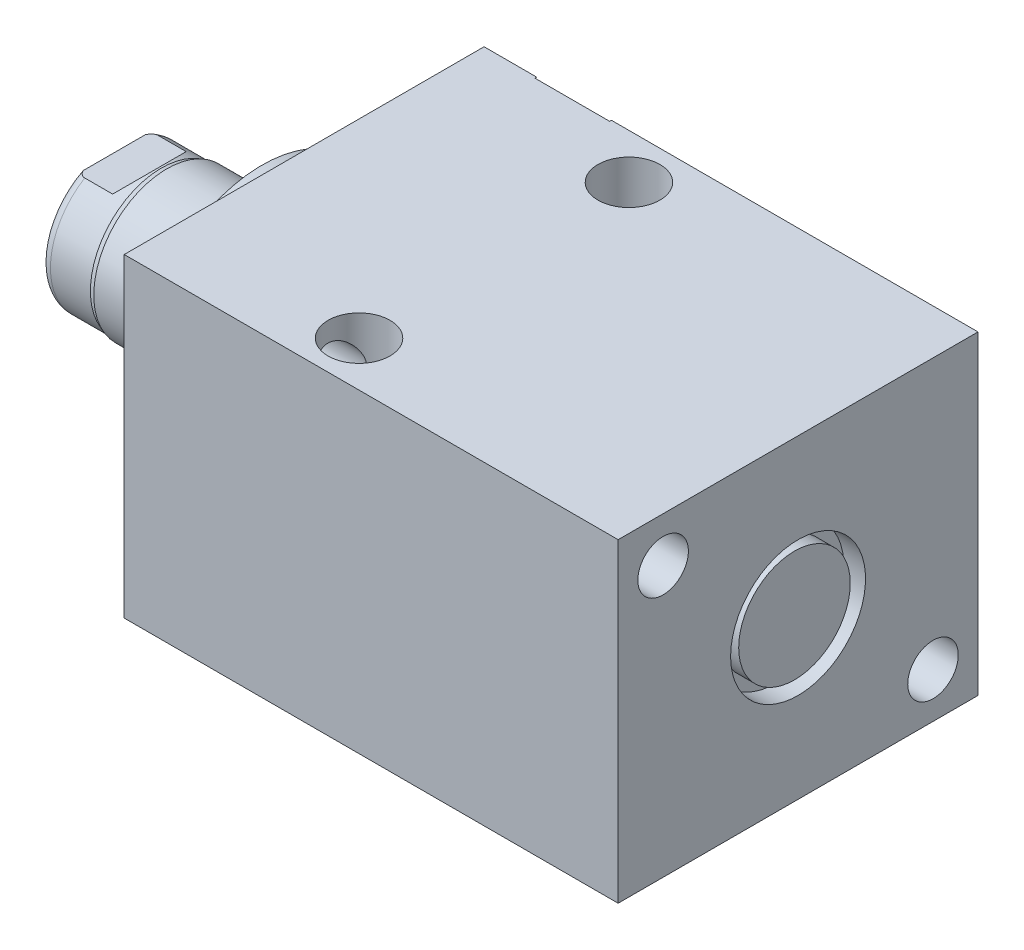
from build123d import *

# Parameters (mm, degrees)
SKETCH1_W          = 50.8
SKETCH1_H          = 44.45
EXTRUDE1_DEPTH     = 69.723
SKETCH5_R          = 17.4625
EXTRUDE2_DEPTH     = 5.969
SKETCH6_W          = 10.31875
SKETCH6_H          = 20.828
CUT_EXTRUDE4_DEPTH = 30.48
SKETCH13_R         = 7.874
EXTRUDE3_DEPTH     = 2.54
HOLE1_D            = 7.1374
HOLE1_DEPTH        = 69.723
HOLE2_D            = 8.7376
HOLE2_DEPTH        = 44.45
SKETCH18_R         = 7.874
EXTRUDE4_DEPTH     = 2.54


with BuildPart() as part:
    # Sketch1 → Extrude1 (new body)
    with BuildSketch(Plane(origin=(0, 0, 0), x_dir=(0, 0, -1), z_dir=(1, 0, 0))):
        Rectangle(SKETCH1_W, SKETCH1_H)
    extrude(amount=EXTRUDE1_DEPTH)

    # S2D0002 → Cut-Revolve1 (revolve, cut)
    with BuildSketch(Plane(origin=(0, 14.3002, 0), x_dir=(-1, 0, 0), z_dir=(0, 1, 0)), mode=Mode.PRIVATE) as cut_revolve1_sk:
        Polygon((-18.8849, -25.146), (-22.225, -25.146), (-22.225, -25.4), (-12.7, -25.4), (-12.7, -11.176), (-17.6784, -11.176), (-17.6784, -21.929393135), (-18.342306865, -22.5933), align=None)
    revolve(cut_revolve1_sk.sketch.rotate(Axis((12.7, 14.3002, -19.13842003), (0, 0, 1)), 180), axis=Axis((12.7, 14.3002, -19.13842003), (0, 0, 1)), mode=Mode.SUBTRACT)  # turned: the seam where the file's is

    # Sketch3 → Cut-Revolve2 (revolve, cut)
    with BuildSketch(Plane(origin=(41.148, 0, -25.146), x_dir=(1, 0, 0), z_dir=(0, 1, 0))):
        Polygon((18.8849, 0), (22.225, 0), (22.225, 0.254), (12.7, 0.254), (12.7, -13.97), (17.6784, -13.97), (17.6784, -3.216606865), (18.342306865, -2.5527), align=None)
    revolve(axis=Axis((53.848, 0, -3.189624441), (0, 0, -1)), mode=Mode.SUBTRACT)

    # Sketch4 → Cut-Revolve3 (revolve, cut)
    with BuildSketch(Plane(origin=(53.975, 0, 0), x_dir=(0, -1, 0), z_dir=(0, 0, 1)), mode=Mode.PRIVATE) as cut_revolve3_sk:
        Polygon((6.1849, 12.7), (9.525, 12.7), (9.525, 15.748), (0, 15.748), (0, 1.3462), (4.9784, 1.3462), (4.9784, 9.483393135), (5.642306865, 10.1473), align=None)
    revolve(cut_revolve3_sk.sketch.rotate(Axis((38.879609832, 0, 0), (1, 0, 0)), 270), axis=Axis((38.879609832, 0, 0), (1, 0, 0)), mode=Mode.SUBTRACT)  # turned: the seam where the file's is

    # Sketch5 → Extrude2 (add)
    with BuildSketch(Plane.ZY):
        Circle(SKETCH5_R)
    extrude(amount=EXTRUDE2_DEPTH)

    # Sketch6 → Revolve1 (revolve)
    with BuildSketch(Plane(origin=(0, 0, 0), x_dir=(0, 0, 1), z_dir=(0, -1, 0)), mode=Mode.PRIVATE) as revolve1_sk:
        with Locations((-5.159375, 16.383)):
            Rectangle(SKETCH6_W, SKETCH6_H)
    revolve(revolve1_sk.sketch.rotate(Axis((5.754582971, 0, 0), (-1, 0, 0)), 180), axis=Axis((5.754582971, 0, 0), (-1, 0, 0)))  # turned: the seam where the file's is

    # S2D0001 → Cut-Revolve4 (revolve, cut)
    with BuildSketch(Plane(origin=(-18.511260017, 3.2639, 0), x_dir=(0, 1, 0), z_dir=(0, 0, 1)), mode=Mode.PRIVATE) as cut_revolve4_sk:
        Polygon((0, 6.35), (0, -6.522460017), (-3.2639, -6.522460017), (-3.2639, 8.285739983), (1.1176, 8.285739983), align=None)
    revolve(cut_revolve4_sk.sketch.rotate(Axis((0, 0, 0), (-1, 0, 0)), 270), axis=Axis((0, 0, 0), (-1, 0, 0)), mode=Mode.SUBTRACT)  # turned: the seam where the file's is

    # Sketch8 → Cut-Revolve5 (revolve, cut)
    with BuildSketch(Plane(origin=(0, 0, 0), x_dir=(0, 0, -1), z_dir=(0, 1, 0)), mode=Mode.PRIVATE) as cut_revolve5_sk:
        with BuildLine():
            Line((-10.31875, 19.3802), (-10.033, 20.1422))
            Line((-10.033, 20.1422), (-10.033, 25.781))
            ThreePointArc((-10.033, 25.781), (-9.932678675, 26.324796865), (-9.644922533, 26.797))
            Line((-9.644922533, 26.797), (-10.31875, 26.797))
            Line((-10.31875, 26.797), (-10.31875, 19.3802))
        make_face()
    revolve(cut_revolve5_sk.sketch.rotate(Axis((-12.65936, 0, 0), (-1, 0, 0)), 180), axis=Axis((-12.65936, 0, 0), (-1, 0, 0)), mode=Mode.SUBTRACT)  # turned: the seam where the file's is

    # Sketch12 → Cut-Extrude4 (cut, symmetric)
    with BuildSketch(Plane(origin=(0, 0, 0), x_dir=(0, -1, 0), z_dir=(0, 0, -1))):
        Polygon((8.5852, 26.797), (8.5852, 21.844), (10.033, 20.3962), (10.033, 26.797), align=None)
        Polygon((-8.5852, 26.797), (-8.5852, 21.844), (-10.033, 20.3962), (-10.033, 26.797), align=None)
    extrude(amount=CUT_EXTRUDE4_DEPTH, both=True, mode=Mode.SUBTRACT)

    # Sketch13 → Extrude3 (add)
    with BuildSketch(Plane(origin=(0, 0, -25.146), x_dir=(-1, 0, 0), z_dir=(0, 0, -1))):
        with Locations(Location((-53.848, 0, 0), (0, 0, 180))):  # turned: the seam where the file's is
            Circle(SKETCH13_R)
    extrude(amount=EXTRUDE3_DEPTH)

    # Hole1
    with Locations(Plane.ZY):
        with Locations((-19.05, -15.875), (19.05, 15.875)):
            Hole(HOLE1_D / 2, depth=HOLE1_DEPTH)

    # Hole2
    with Locations(Plane(origin=(0, 22.225, 0), x_dir=(-1, 0, 0), z_dir=(0, 1, 0))):
        with Locations((-26.797, -19.05), (-26.797, 19.05)):
            Hole(HOLE2_D / 2, depth=HOLE2_DEPTH)

    # Sketch18 → Extrude4 (add)
    with BuildSketch(Plane(origin=(66.675, 0, 0), x_dir=(0, 0, -1), z_dir=(1, 0, 0))):
        with Locations(Location((0, 0, 0), (0, 0, 180))):  # turned: the seam where the file's is
            Circle(SKETCH18_R)
    extrude(amount=EXTRUDE4_DEPTH)


solid = part.part
